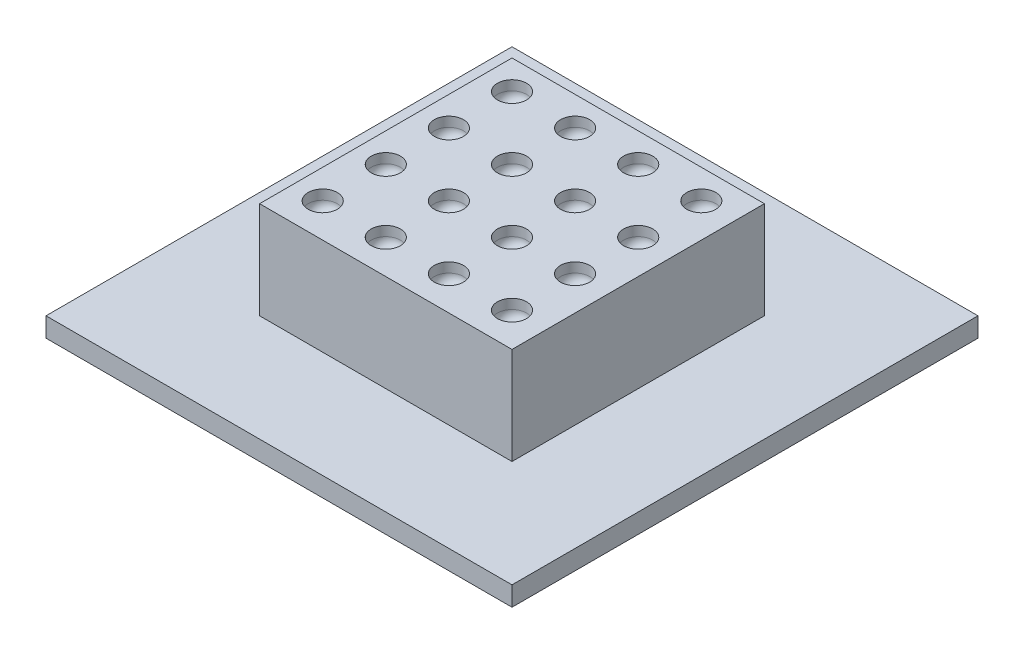
from build123d import *

# Parameters (mm, degrees)
SKETCH1_W              = 13
SKETCH1_H              = 13
BOSS_EXTRUDE1_DEPTH    = 5
SKETCH2_W              = 24
SKETCH2_H              = 24
BOSS_EXTRUDE2_DEPTH    = 1
SKETCH3_R              = 0.75
CUT_EXTRUDE1_DEPTH     = 1
FILLET1_R              = 0.5
LPATTERN1_COUNT        = 4
LPATTERN1_PITCH        = 3.25
LPATTERN1_COUNT_DIR2   = 4
LPATTERN1_PITCH_DIR2   = 3.25
FILLET1_OF_LPATTERN1_R = 0.5


with BuildPart() as part:
    # Sketch1 → Boss-Extrude1 (new body)
    with BuildSketch(Plane(origin=(0, 0, 0), x_dir=(1, 0, 0), z_dir=(0, 1, 0))):
        Rectangle(SKETCH1_W, SKETCH1_H)
    extrude(amount=BOSS_EXTRUDE1_DEPTH)

    # Sketch2 → Boss-Extrude2 (add)
    with BuildSketch(Plane.XZ):
        Rectangle(SKETCH2_W, SKETCH2_H)
    extrude(amount=BOSS_EXTRUDE2_DEPTH)

    # Sketch3 → Cut-Extrude1 (cut)
    with BuildSketch(Plane(origin=(0, 5, 0), x_dir=(1, 0, 0), z_dir=(0, 1, 0))):
        with Locations((-5, 5)):
            Circle(SKETCH3_R)
    cut_extrude1 = extrude(amount=-CUT_EXTRUDE1_DEPTH, mode=Mode.SUBTRACT)

    # Fillet1
    fillet1_edges = [part.edges().sort_by_distance(p)[0] for p in [
        (-5.75, 4, -5),
    ]]
    fillet(fillet1_edges, radius=FILLET1_R)

    # LPattern1: Cut-Extrude1 4 × 4
    with Locations(*[(i * LPATTERN1_PITCH, 0, j * LPATTERN1_PITCH_DIR2) for i in range(LPATTERN1_COUNT) for j in range(LPATTERN1_COUNT_DIR2) if (i, j) != (0, 0)]):
        add(cut_extrude1, mode=Mode.SUBTRACT)

    # Fillet1 of LPattern1
    fillet1_of_lpattern1_edges = [part.edges().sort_by_distance(p)[0] for p in [
        (-5.75, 4, -1.75),
        (-5.75, 4, 1.5),
        (-5.75, 4, 4.75),
        (-2.5, 4, -5),
        (-2.5, 4, -1.75),
        (-2.5, 4, 1.5),
        (-2.5, 4, 4.75),
        (0.75, 4, -5),
        (0.75, 4, -1.75),
        (0.75, 4, 1.5),
        (0.75, 4, 4.75),
        (4, 4, -5),
        (4, 4, -1.75),
        (4, 4, 1.5),
        (4, 4, 4.75),
    ]]
    fillet(fillet1_of_lpattern1_edges, radius=FILLET1_OF_LPATTERN1_R)


solid = part.part
